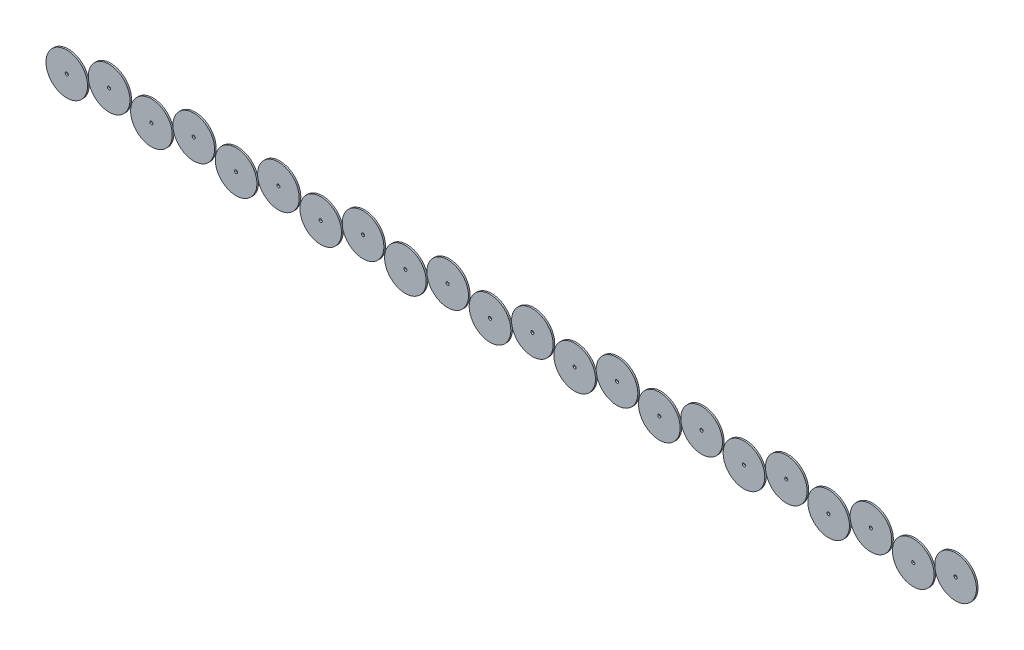
from build123d import *

# Parameters (mm, degrees)
SKETCH1_R              = 19.685
SKETCH1_R_2            = 1.4732
BOSS_EXTRUDE1_DEPTH    = 1.524
BOSS_EXTRUDE1_2_DEPTH  = 1.524
BOSS_EXTRUDE1_3_DEPTH  = 1.524
BOSS_EXTRUDE1_4_DEPTH  = 1.524
BOSS_EXTRUDE1_5_DEPTH  = 1.524
BOSS_EXTRUDE1_6_DEPTH  = 1.524
BOSS_EXTRUDE1_7_DEPTH  = 1.524
BOSS_EXTRUDE1_8_DEPTH  = 1.524
BOSS_EXTRUDE1_9_DEPTH  = 1.524
BOSS_EXTRUDE1_10_DEPTH = 1.524
BOSS_EXTRUDE1_11_DEPTH = 1.524
BOSS_EXTRUDE1_12_DEPTH = 1.524
BOSS_EXTRUDE1_13_DEPTH = 1.524
BOSS_EXTRUDE1_14_DEPTH = 1.524
BOSS_EXTRUDE1_15_DEPTH = 1.524
BOSS_EXTRUDE1_16_DEPTH = 1.524
BOSS_EXTRUDE1_17_DEPTH = 1.524
BOSS_EXTRUDE1_18_DEPTH = 1.524
BOSS_EXTRUDE1_19_DEPTH = 1.524
BOSS_EXTRUDE1_20_DEPTH = 1.524
BOSS_EXTRUDE1_21_DEPTH = 1.524
BOSS_EXTRUDE1_22_DEPTH = 1.524


with BuildPart() as part:
    # Sketch1 → Boss-Extrude1 (new body)
    with BuildSketch(Plane.XY):
        with Locations((-435.991, -4.191)):
            Circle(SKETCH1_R)
        with Locations((-435.991, -4.191)):
            Circle(SKETCH1_R_2, mode=Mode.SUBTRACT)
    extrude(amount=BOSS_EXTRUDE1_DEPTH)


with BuildPart() as body_2:
    # Sketch1 → Boss-Extrude1 2 (new body)
    with BuildSketch(Plane.XY):
        with Locations((-395.965241894, 4.191)):
            Circle(SKETCH1_R)
        with Locations((-395.965241894, 4.191)):
            Circle(SKETCH1_R_2, mode=Mode.SUBTRACT)
    extrude(amount=BOSS_EXTRUDE1_2_DEPTH)


with BuildPart() as body_3:
    # Sketch1 → Boss-Extrude1 3 (new body)
    with BuildSketch(Plane.XY):
        with Locations((-355.939483787, -4.191)):
            Circle(SKETCH1_R)
        with Locations((-355.939483787, -4.191)):
            Circle(SKETCH1_R_2, mode=Mode.SUBTRACT)
    extrude(amount=BOSS_EXTRUDE1_3_DEPTH)


with BuildPart() as body_4:
    # Sketch1 → Boss-Extrude1 4 (new body)
    with BuildSketch(Plane.XY):
        with Locations((-315.913725681, 4.191)):
            Circle(SKETCH1_R)
        with Locations((-315.913725681, 4.191)):
            Circle(SKETCH1_R_2, mode=Mode.SUBTRACT)
    extrude(amount=BOSS_EXTRUDE1_4_DEPTH)


with BuildPart() as body_5:
    # Sketch1 → Boss-Extrude1 5 (new body)
    with BuildSketch(Plane.XY):
        with Locations((-275.887967574, -4.191)):
            Circle(SKETCH1_R)
        with Locations((-275.887967574, -4.191)):
            Circle(SKETCH1_R_2, mode=Mode.SUBTRACT)
    extrude(amount=BOSS_EXTRUDE1_5_DEPTH)


with BuildPart() as body_6:
    # Sketch1 → Boss-Extrude1 6 (new body)
    with BuildSketch(Plane.XY):
        with Locations((-235.862209468, 4.191)):
            Circle(SKETCH1_R)
        with Locations((-235.862209468, 4.191)):
            Circle(SKETCH1_R_2, mode=Mode.SUBTRACT)
    extrude(amount=BOSS_EXTRUDE1_6_DEPTH)


with BuildPart() as body_7:
    # Sketch1 → Boss-Extrude1 7 (new body)
    with BuildSketch(Plane.XY):
        with Locations((-195.836451361, -4.191)):
            Circle(SKETCH1_R)
        with Locations((-195.836451361, -4.191)):
            Circle(SKETCH1_R_2, mode=Mode.SUBTRACT)
    extrude(amount=BOSS_EXTRUDE1_7_DEPTH)


with BuildPart() as body_8:
    # Sketch1 → Boss-Extrude1 8 (new body)
    with BuildSketch(Plane.XY):
        with Locations((-155.810693255, 4.191)):
            Circle(SKETCH1_R)
        with Locations((-155.810693255, 4.191)):
            Circle(SKETCH1_R_2, mode=Mode.SUBTRACT)
    extrude(amount=BOSS_EXTRUDE1_8_DEPTH)


with BuildPart() as body_9:
    # Sketch1 → Boss-Extrude1 9 (new body)
    with BuildSketch(Plane.XY):
        with Locations((-115.784935148, -4.191)):
            Circle(SKETCH1_R)
        with Locations((-115.784935148, -4.191)):
            Circle(SKETCH1_R_2, mode=Mode.SUBTRACT)
    extrude(amount=BOSS_EXTRUDE1_9_DEPTH)


with BuildPart() as body_10:
    # Sketch1 → Boss-Extrude1 10 (new body)
    with BuildSketch(Plane.XY):
        with Locations((-75.759177042, 4.191)):
            Circle(SKETCH1_R)
        with Locations((-75.759177042, 4.191)):
            Circle(SKETCH1_R_2, mode=Mode.SUBTRACT)
    extrude(amount=BOSS_EXTRUDE1_10_DEPTH)


with BuildPart() as body_11:
    # Sketch1 → Boss-Extrude1 11 (new body)
    with BuildSketch(Plane.XY):
        with Locations((-35.733418935, -4.191)):
            Circle(SKETCH1_R)
        with Locations((-35.733418935, -4.191)):
            Circle(SKETCH1_R_2, mode=Mode.SUBTRACT)
    extrude(amount=BOSS_EXTRUDE1_11_DEPTH)


with BuildPart() as body_12:
    # Sketch1 → Boss-Extrude1 12 (new body)
    with BuildSketch(Plane.XY):
        with Locations((4.292339171, 4.191)):
            Circle(SKETCH1_R)
        with Locations((4.292339171, 4.191)):
            Circle(SKETCH1_R_2, mode=Mode.SUBTRACT)
    extrude(amount=BOSS_EXTRUDE1_12_DEPTH)


with BuildPart() as body_13:
    # Sketch1 → Boss-Extrude1 13 (new body)
    with BuildSketch(Plane.XY):
        with Locations((44.318097278, -4.191)):
            Circle(SKETCH1_R)
        with Locations((44.318097278, -4.191)):
            Circle(SKETCH1_R_2, mode=Mode.SUBTRACT)
    extrude(amount=BOSS_EXTRUDE1_13_DEPTH)


with BuildPart() as body_14:
    # Sketch1 → Boss-Extrude1 14 (new body)
    with BuildSketch(Plane.XY):
        with Locations((84.343855384, 4.191)):
            Circle(SKETCH1_R)
        with Locations((84.343855384, 4.191)):
            Circle(SKETCH1_R_2, mode=Mode.SUBTRACT)
    extrude(amount=BOSS_EXTRUDE1_14_DEPTH)


with BuildPart() as body_15:
    # Sketch1 → Boss-Extrude1 15 (new body)
    with BuildSketch(Plane.XY):
        with Locations((124.369613491, -4.191)):
            Circle(SKETCH1_R)
        with Locations((124.369613491, -4.191)):
            Circle(SKETCH1_R_2, mode=Mode.SUBTRACT)
    extrude(amount=BOSS_EXTRUDE1_15_DEPTH)


with BuildPart() as body_16:
    # Sketch1 → Boss-Extrude1 16 (new body)
    with BuildSketch(Plane.XY):
        with Locations((164.395371597, 4.191)):
            Circle(SKETCH1_R)
        with Locations((164.395371597, 4.191)):
            Circle(SKETCH1_R_2, mode=Mode.SUBTRACT)
    extrude(amount=BOSS_EXTRUDE1_16_DEPTH)


with BuildPart() as body_17:
    # Sketch1 → Boss-Extrude1 17 (new body)
    with BuildSketch(Plane.XY):
        with Locations((204.421129704, -4.191)):
            Circle(SKETCH1_R)
        with Locations((204.421129704, -4.191)):
            Circle(SKETCH1_R_2, mode=Mode.SUBTRACT)
    extrude(amount=BOSS_EXTRUDE1_17_DEPTH)


with BuildPart() as body_18:
    # Sketch1 → Boss-Extrude1 18 (new body)
    with BuildSketch(Plane.XY):
        with Locations((244.44688781, 4.191)):
            Circle(SKETCH1_R)
        with Locations((244.44688781, 4.191)):
            Circle(SKETCH1_R_2, mode=Mode.SUBTRACT)
    extrude(amount=BOSS_EXTRUDE1_18_DEPTH)


with BuildPart() as body_19:
    # Sketch1 → Boss-Extrude1 19 (new body)
    with BuildSketch(Plane.XY):
        with Locations((284.472645917, -4.191)):
            Circle(SKETCH1_R)
        with Locations((284.472645917, -4.191)):
            Circle(SKETCH1_R_2, mode=Mode.SUBTRACT)
    extrude(amount=BOSS_EXTRUDE1_19_DEPTH)


with BuildPart() as body_20:
    # Sketch1 → Boss-Extrude1 20 (new body)
    with BuildSketch(Plane.XY):
        with Locations((324.498404023, 4.191)):
            Circle(SKETCH1_R)
        with Locations((324.498404023, 4.191)):
            Circle(SKETCH1_R_2, mode=Mode.SUBTRACT)
    extrude(amount=BOSS_EXTRUDE1_20_DEPTH)


with BuildPart() as body_21:
    # Sketch1 → Boss-Extrude1 21 (new body)
    with BuildSketch(Plane.XY):
        with Locations((364.52416213, -4.191)):
            Circle(SKETCH1_R)
        with Locations((364.52416213, -4.191)):
            Circle(SKETCH1_R_2, mode=Mode.SUBTRACT)
    extrude(amount=BOSS_EXTRUDE1_21_DEPTH)


with BuildPart() as body_22:
    # Sketch1 → Boss-Extrude1 22 (new body)
    with BuildSketch(Plane.XY):
        with Locations((404.549920236, 4.191)):
            Circle(SKETCH1_R)
        with Locations((404.549920236, 4.191)):
            Circle(SKETCH1_R_2, mode=Mode.SUBTRACT)
    extrude(amount=BOSS_EXTRUDE1_22_DEPTH)


solid = Compound([part.part, body_2.part, body_3.part, body_4.part, body_5.part, body_6.part, body_7.part, body_8.part, body_9.part, body_10.part, body_11.part, body_12.part, body_13.part, body_14.part, body_15.part, body_16.part, body_17.part, body_18.part, body_19.part, body_20.part, body_21.part, body_22.part])
